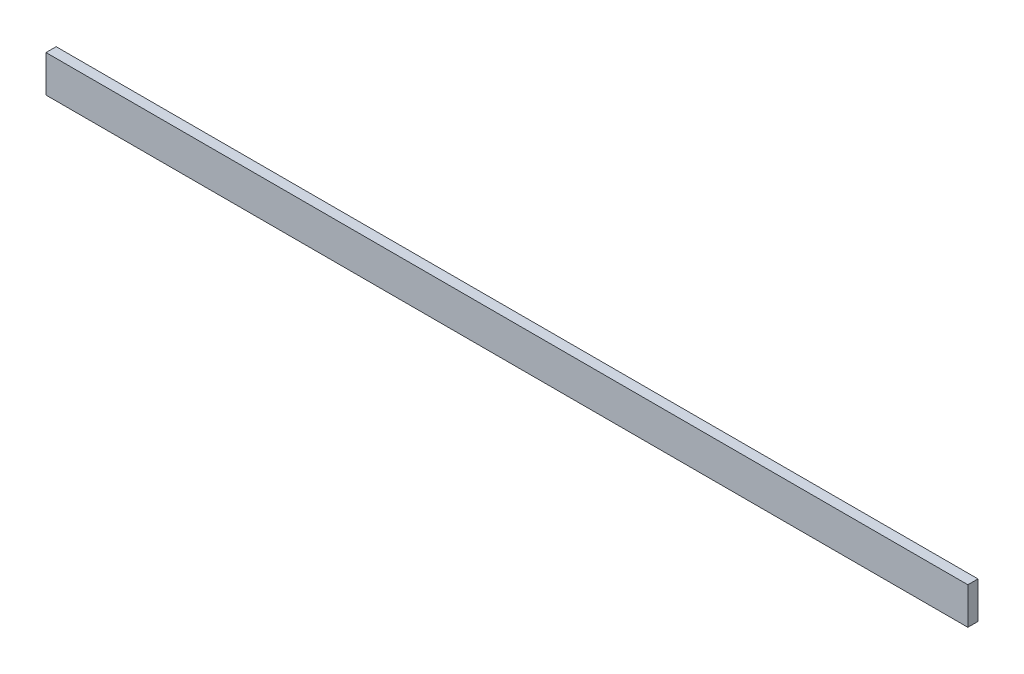
from build123d import *

# Parameters (mm, degrees)
ESQUISSE1_W      = 2000
ESQUISSE1_H      = 80
EXTRUSION1_DEPTH = 22


with BuildPart() as part:
    # Esquisse1 → Extrusion1 (new body)
    with BuildSketch(Plane.XY):
        with Locations((1000, 40)):
            Rectangle(ESQUISSE1_W, ESQUISSE1_H)
    extrude(amount=EXTRUSION1_DEPTH)


solid = part.part
